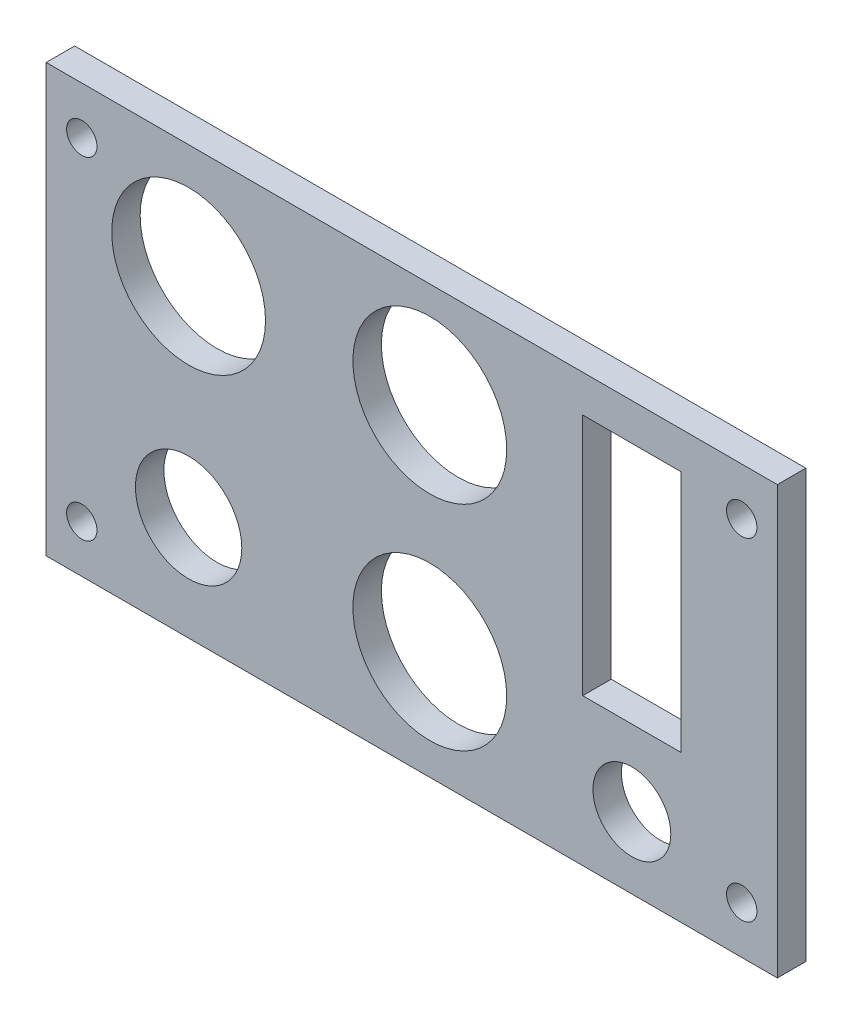
from build123d import *

# Parameters (mm, degrees)
CROQUIS1_W              = 77
CROQUIS1_H              = 45
SALIENTE_EXTRUIR1_DEPTH = 3
CORTAR_EXTRUIR1_REACH   = 5
CROQUIS2_R              = 8.1
CROQUIS2_R_2            = 5.6
CROQUIS2_R_3            = 4.1
CROQUIS2_R_4            = 1.6
CROQUIS2_W              = 10.36
CROQUIS2_H              = 25.6


with BuildPart() as part:
    # Croquis1 → Saliente-Extruir1 (new body)
    with BuildSketch(Plane.XY):
        with Locations((38.5, 22.5)):
            Rectangle(CROQUIS1_W, CROQUIS1_H)
    extrude(amount=SALIENTE_EXTRUIR1_DEPTH)

    # Croquis2 → Cortar-Extruir1 (cut, up to next)
    with BuildSketch(Plane.XY.offset(3), mode=Mode.PRIVATE) as cortar_extruir1_sk1:
        with Locations((15, 33)):
            Circle(CROQUIS2_R)
    cortar_extruir1_tool1 = extrude(cortar_extruir1_sk1.sketch, amount=-CORTAR_EXTRUIR1_REACH, mode=Mode.PRIVATE) & part.part
    add(cortar_extruir1_tool1.solids().sort_by_distance((15, 33, 3))[0], mode=Mode.SUBTRACT)
    # Croquis2 → Cortar-Extruir1 (cut, up to next)
    with BuildSketch(Plane.XY.offset(3), mode=Mode.PRIVATE) as cortar_extruir1_sk2:
        with Locations((15, 11)):
            Circle(CROQUIS2_R_2)
    cortar_extruir1_tool2 = extrude(cortar_extruir1_sk2.sketch, amount=-CORTAR_EXTRUIR1_REACH, mode=Mode.PRIVATE) & part.part
    add(cortar_extruir1_tool2.solids().sort_by_distance((15, 11, 3))[0], mode=Mode.SUBTRACT)
    # Croquis2 → Cortar-Extruir1 (cut, up to next)
    with BuildSketch(Plane.XY.offset(3), mode=Mode.PRIVATE) as cortar_extruir1_sk3:
        with Locations((61.68, 7.5)):
            Circle(CROQUIS2_R_3)
    cortar_extruir1_tool3 = extrude(cortar_extruir1_sk3.sketch, amount=-CORTAR_EXTRUIR1_REACH, mode=Mode.PRIVATE) & part.part
    add(cortar_extruir1_tool3.solids().sort_by_distance((61.68, 7.5, 3))[0], mode=Mode.SUBTRACT)
    # Croquis2 → Cortar-Extruir1 (cut, up to next)
    with BuildSketch(Plane.XY.offset(3), mode=Mode.PRIVATE) as cortar_extruir1_sk4:
        with Locations((40.4, 33.95)):
            Circle(CROQUIS2_R)
    cortar_extruir1_tool4 = extrude(cortar_extruir1_sk4.sketch, amount=-CORTAR_EXTRUIR1_REACH, mode=Mode.PRIVATE) & part.part
    add(cortar_extruir1_tool4.solids().sort_by_distance((40.4, 33.95, 3))[0], mode=Mode.SUBTRACT)
    # Croquis2 → Cortar-Extruir1 (cut, up to next)
    with BuildSketch(Plane.XY.offset(3), mode=Mode.PRIVATE) as cortar_extruir1_sk5:
        with Locations((40.4, 11.45)):
            Circle(CROQUIS2_R)
    cortar_extruir1_tool5 = extrude(cortar_extruir1_sk5.sketch, amount=-CORTAR_EXTRUIR1_REACH, mode=Mode.PRIVATE) & part.part
    add(cortar_extruir1_tool5.solids().sort_by_distance((40.4, 11.45, 3))[0], mode=Mode.SUBTRACT)
    # Croquis2 → Cortar-Extruir1 (cut, up to next)
    with BuildSketch(Plane.XY.offset(3), mode=Mode.PRIVATE) as cortar_extruir1_sk6:
        with Locations((73.25, 40)):
            Circle(CROQUIS2_R_4)
    cortar_extruir1_tool6 = extrude(cortar_extruir1_sk6.sketch, amount=-CORTAR_EXTRUIR1_REACH, mode=Mode.PRIVATE) & part.part
    add(cortar_extruir1_tool6.solids().sort_by_distance((73.25, 40, 3))[0], mode=Mode.SUBTRACT)
    # Croquis2 → Cortar-Extruir1 (cut, up to next)
    with BuildSketch(Plane.XY.offset(3), mode=Mode.PRIVATE) as cortar_extruir1_sk7:
        with Locations((73.25, 5)):
            Circle(CROQUIS2_R_4)
    cortar_extruir1_tool7 = extrude(cortar_extruir1_sk7.sketch, amount=-CORTAR_EXTRUIR1_REACH, mode=Mode.PRIVATE) & part.part
    add(cortar_extruir1_tool7.solids().sort_by_distance((73.25, 5, 3))[0], mode=Mode.SUBTRACT)
    # Croquis2 → Cortar-Extruir1 (cut, up to next)
    with BuildSketch(Plane.XY.offset(3), mode=Mode.PRIVATE) as cortar_extruir1_sk8:
        with Locations((3.75, 5)):
            Circle(CROQUIS2_R_4)
    cortar_extruir1_tool8 = extrude(cortar_extruir1_sk8.sketch, amount=-CORTAR_EXTRUIR1_REACH, mode=Mode.PRIVATE) & part.part
    add(cortar_extruir1_tool8.solids().sort_by_distance((3.75, 5, 3))[0], mode=Mode.SUBTRACT)
    # Croquis2 → Cortar-Extruir1 (cut, up to next)
    with BuildSketch(Plane.XY.offset(3), mode=Mode.PRIVATE) as cortar_extruir1_sk9:
        with Locations((3.75, 40)):
            Circle(CROQUIS2_R_4)
    cortar_extruir1_tool9 = extrude(cortar_extruir1_sk9.sketch, amount=-CORTAR_EXTRUIR1_REACH, mode=Mode.PRIVATE) & part.part
    add(cortar_extruir1_tool9.solids().sort_by_distance((3.75, 40, 3))[0], mode=Mode.SUBTRACT)
    # Croquis2 → Cortar-Extruir1 (cut, up to next)
    with BuildSketch(Plane.XY.offset(3), mode=Mode.PRIVATE) as cortar_extruir1_sk10:
        with Locations((61.68, 28.3)):
            Rectangle(CROQUIS2_W, CROQUIS2_H)
    cortar_extruir1_tool10 = extrude(cortar_extruir1_sk10.sketch, amount=-CORTAR_EXTRUIR1_REACH, mode=Mode.PRIVATE) & part.part
    add(cortar_extruir1_tool10.solids().sort_by_distance((61.68, 28.3, 3))[0], mode=Mode.SUBTRACT)


solid = part.part
